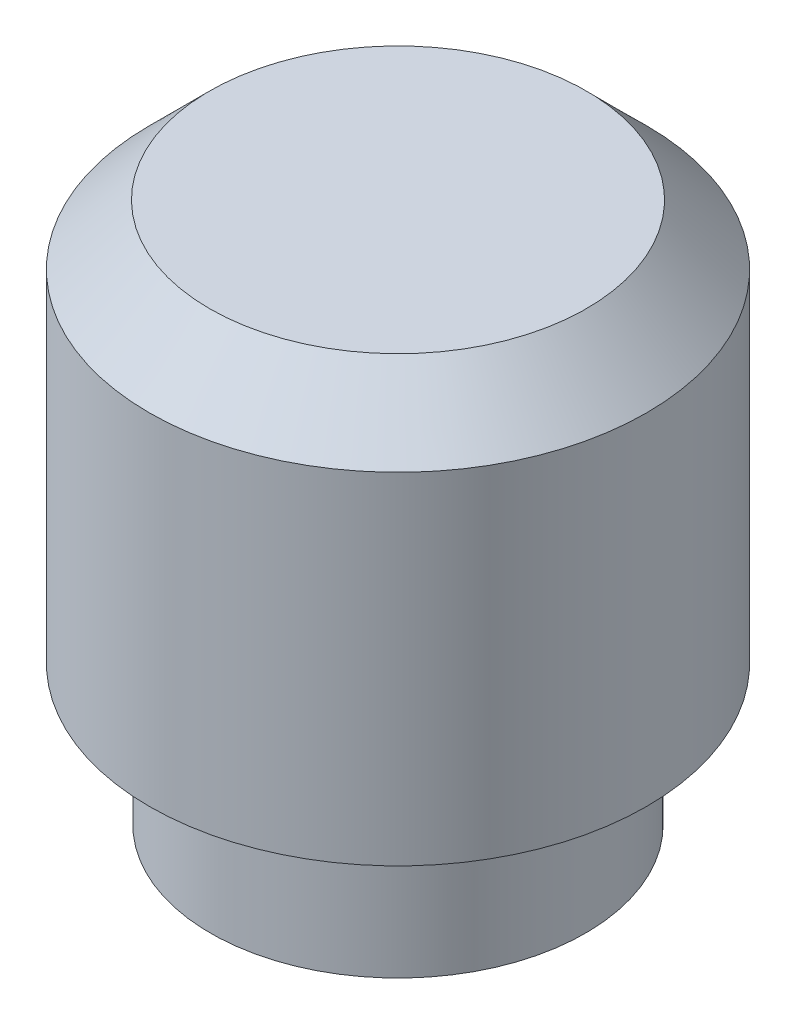
from build123d import *

# Parameters (mm, degrees)
FILLET1_R     = 0.127
CHAMFER1_SIZE = 0.762


with BuildPart() as part:
    # Sketch1 → Revolve1 (revolve)
    with BuildSketch(Plane.XY):
        Polygon((0, 6.858), (3.1496, 6.858), (3.1496, 1.778), (2.3749, 1.778), (2.3749, 0), (1.524, 0), (1.524, 1.778), (0, 2.726975536), align=None)
    revolve(axis=Axis((0, 0, 0), (0, 1, 0)))

    # Fillet1
    fillet1_edges = [part.edges().sort_by_distance(p)[0] for p in [
        (-2.3749, 1.778, 0),
    ]]
    fillet(fillet1_edges, radius=FILLET1_R)

    # Chamfer1
    chamfer1_edges = [part.edges().sort_by_distance(p)[0] for p in [
        (-3.1496, 6.858, 0),
    ]]
    chamfer(chamfer1_edges, length=CHAMFER1_SIZE)


solid = part.part
